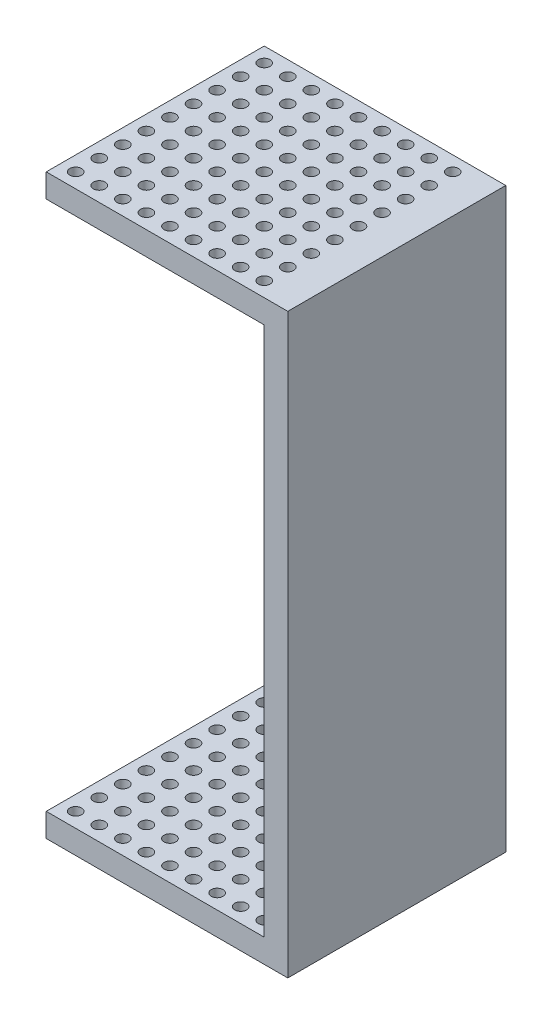
from build123d import *

# Parameters (mm, degrees)
SKETCH1_W           = 20.5
SKETCH1_H           = 18.5
BOSS_EXTRUDE1_DEPTH = 2
SKETCH2_W           = 2
SKETCH2_H           = 18.5
BOSS_EXTRUDE2_DEPTH = 45
SKETCH4_W           = 20.5
SKETCH4_H           = 18.5
BOSS_EXTRUDE3_DEPTH = 2
SKETCH3_R           = 0.5
CUT_EXTRUDE1_DEPTH  = 50


with BuildPart() as part:
    # Sketch1 → Boss-Extrude1 (new body)
    with BuildSketch(Plane(origin=(0, 0, 0), x_dir=(1, 0, 0), z_dir=(0, 1, 0))):
        Rectangle(SKETCH1_W, SKETCH1_H)
    extrude(amount=BOSS_EXTRUDE1_DEPTH)

    # Sketch2 → Boss-Extrude2 (add)
    with BuildSketch(Plane(origin=(0, 2, 0), x_dir=(1, 0, 0), z_dir=(0, 1, 0))):
        with Locations((9.25, 0)):
            Rectangle(SKETCH2_W, SKETCH2_H)
    extrude(amount=BOSS_EXTRUDE2_DEPTH)

    # Sketch4 → Boss-Extrude3 (add)
    with BuildSketch(Plane(origin=(0, 47, 0), x_dir=(1, 0, 0), z_dir=(0, 1, 0))):
        Rectangle(SKETCH4_W, SKETCH4_H)
    extrude(amount=BOSS_EXTRUDE3_DEPTH)

    # Sketch3 → Cut-Extrude1 (cut, through all)
    with BuildSketch(Plane.XZ):
        with Locations((-9, 8)):
            Circle(SKETCH3_R)
        with Locations((-7, 8)):
            Circle(SKETCH3_R)
        with Locations((-5, 8)):
            Circle(SKETCH3_R)
        with Locations((-3, 8)):
            Circle(SKETCH3_R)
        with Locations((-1, 8)):
            Circle(SKETCH3_R)
        with Locations((1, 8)):
            Circle(SKETCH3_R)
        with Locations((3, 8)):
            Circle(SKETCH3_R)
        with Locations((5, 8)):
            Circle(SKETCH3_R)
        with Locations((7, 8)):
            Circle(SKETCH3_R)
        with Locations((-7, 6)):
            Circle(SKETCH3_R)
        with Locations((-5, 6)):
            Circle(SKETCH3_R)
        with Locations((-3, 6)):
            Circle(SKETCH3_R)
        with Locations((-1, 6)):
            Circle(SKETCH3_R)
        with Locations((1, 6)):
            Circle(SKETCH3_R)
        with Locations((3, 6)):
            Circle(SKETCH3_R)
        with Locations((5, 6)):
            Circle(SKETCH3_R)
        with Locations((7, 6)):
            Circle(SKETCH3_R)
        with Locations((-7, 4)):
            Circle(SKETCH3_R)
        with Locations((-5, 4)):
            Circle(SKETCH3_R)
        with Locations((-3, 4)):
            Circle(SKETCH3_R)
        with Locations((-1, 4)):
            Circle(SKETCH3_R)
        with Locations((1, 4)):
            Circle(SKETCH3_R)
        with Locations((3, 4)):
            Circle(SKETCH3_R)
        with Locations((5, 4)):
            Circle(SKETCH3_R)
        with Locations((7, 4)):
            Circle(SKETCH3_R)
        with Locations((-7, 2)):
            Circle(SKETCH3_R)
        with Locations((-5, 2)):
            Circle(SKETCH3_R)
        with Locations((-3, 2)):
            Circle(SKETCH3_R)
        with Locations((-1, 2)):
            Circle(SKETCH3_R)
        with Locations((1, 2)):
            Circle(SKETCH3_R)
        with Locations((3, 2)):
            Circle(SKETCH3_R)
        with Locations((5, 2)):
            Circle(SKETCH3_R)
        with Locations((7, 2)):
            Circle(SKETCH3_R)
        with Locations((-7, 0)):
            Circle(SKETCH3_R)
        with Locations((-5, 0)):
            Circle(SKETCH3_R)
        with Locations((-3, 0)):
            Circle(SKETCH3_R)
        with Locations((-1, 0)):
            Circle(SKETCH3_R)
        with Locations((1, 0)):
            Circle(SKETCH3_R)
        with Locations((3, 0)):
            Circle(SKETCH3_R)
        with Locations((5, 0)):
            Circle(SKETCH3_R)
        with Locations((7, 0)):
            Circle(SKETCH3_R)
        with Locations((-7, -2)):
            Circle(SKETCH3_R)
        with Locations((-5, -2)):
            Circle(SKETCH3_R)
        with Locations((-3, -2)):
            Circle(SKETCH3_R)
        with Locations((-1, -2)):
            Circle(SKETCH3_R)
        with Locations((1, -2)):
            Circle(SKETCH3_R)
        with Locations((3, -2)):
            Circle(SKETCH3_R)
        with Locations((5, -2)):
            Circle(SKETCH3_R)
        with Locations((7, -2)):
            Circle(SKETCH3_R)
        with Locations((-7, -4)):
            Circle(SKETCH3_R)
        with Locations((-5, -4)):
            Circle(SKETCH3_R)
        with Locations((-3, -4)):
            Circle(SKETCH3_R)
        with Locations((-1, -4)):
            Circle(SKETCH3_R)
        with Locations((1, -4)):
            Circle(SKETCH3_R)
        with Locations((3, -4)):
            Circle(SKETCH3_R)
        with Locations((5, -4)):
            Circle(SKETCH3_R)
        with Locations((7, -4)):
            Circle(SKETCH3_R)
        with Locations((-7, -6)):
            Circle(SKETCH3_R)
        with Locations((-5, -6)):
            Circle(SKETCH3_R)
        with Locations((-3, -6)):
            Circle(SKETCH3_R)
        with Locations((-1, -6)):
            Circle(SKETCH3_R)
        with Locations((1, -6)):
            Circle(SKETCH3_R)
        with Locations((3, -6)):
            Circle(SKETCH3_R)
        with Locations((5, -6)):
            Circle(SKETCH3_R)
        with Locations((7, -6)):
            Circle(SKETCH3_R)
        with Locations((-7, -8)):
            Circle(SKETCH3_R)
        with Locations((-5, -8)):
            Circle(SKETCH3_R)
        with Locations((-3, -8)):
            Circle(SKETCH3_R)
        with Locations((-1, -8)):
            Circle(SKETCH3_R)
        with Locations((1, -8)):
            Circle(SKETCH3_R)
        with Locations((3, -8)):
            Circle(SKETCH3_R)
        with Locations((5, -8)):
            Circle(SKETCH3_R)
        with Locations((7, -8)):
            Circle(SKETCH3_R)
        with Locations((-9, 6)):
            Circle(SKETCH3_R)
        with Locations((-9, 4)):
            Circle(SKETCH3_R)
        with Locations((-9, 2)):
            Circle(SKETCH3_R)
        with Locations((-9, 0)):
            Circle(SKETCH3_R)
        with Locations((-9, -2)):
            Circle(SKETCH3_R)
        with Locations((-9, -4)):
            Circle(SKETCH3_R)
        with Locations((-9, -6)):
            Circle(SKETCH3_R)
        with Locations((-9, -8)):
            Circle(SKETCH3_R)
    extrude(amount=-CUT_EXTRUDE1_DEPTH, mode=Mode.SUBTRACT)


solid = part.part
